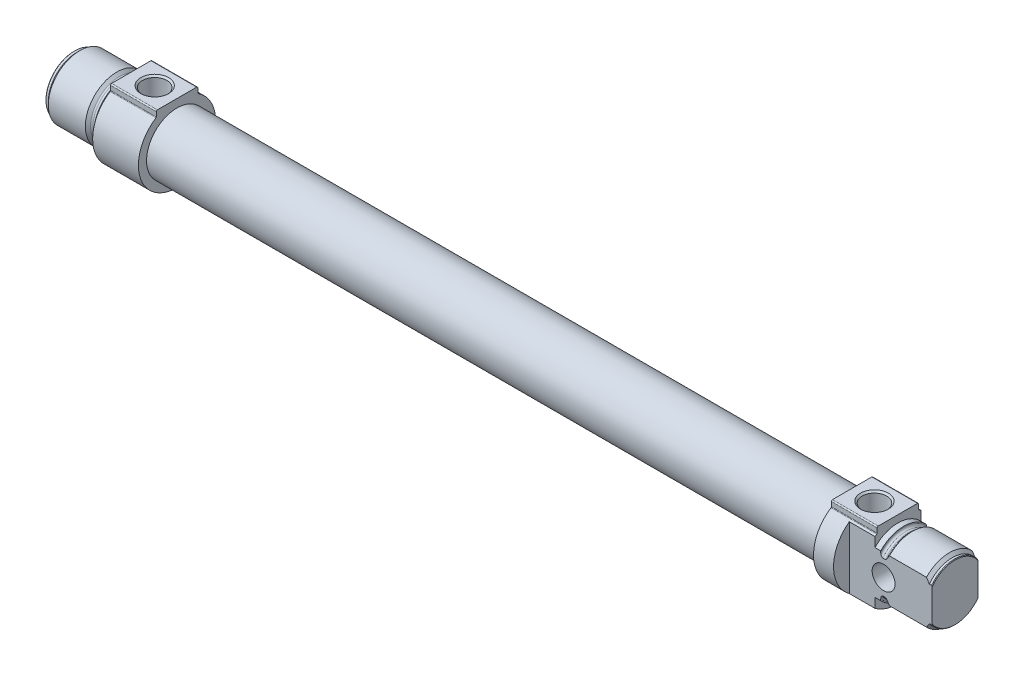
from build123d import *

# Parameters (mm, degrees)
AUFSATZ_LINEAR_AUSTRAGEN1_DEPTH      = 16
SKIZZE3_W                            = 236
SKIZZE3_H                            = 10.65
AUFSATZ_LINEAR_AUSTRAGEN2_DEPTH      = 16
SCHNITT_LINEAR_AUSTRAGEN1_DEPTH      = 13.5
SCHNITT_LINEAR_AUSTRAGEN1_DEPTH_BACK = 13.5
BOHRUNG1_D                           = 8
BOHRUNG2_D                           = 8.566
BOHRUNG2_DEPTH                       = 13.5
BOHRUNG2_CSINK_D                     = 9.728
BOHRUNG2_CSINK_ANGLE                 = 90
BOHRUNG3_D                           = 8.566
BOHRUNG3_DEPTH                       = 16
BOHRUNG3_CSINK_D                     = 9.728
BOHRUNG3_CSINK_ANGLE                 = 90
BOHRUNG3_TIP                         = 2.472791203


with BuildPart() as part:
    # Skizze1 → Rotation1 (revolve)
    with BuildSketch(Plane.XY):
        with BuildLine():
            Line((0, 0), (0, 9.8))
            Line((0, 9.8), (0.2, 10))
            Line((0.2, 10), (1, 10))
            Line((1, 10), (2, 11))
            Line((2, 11), (14.95, 11))
            Line((14.95, 11), (15.865685425, 10.084314575))
            ThreePointArc((15.865685425, 10.084314575), (16.125224104, 9.910896374), (16.43137085, 9.85))
            Line((16.43137085, 9.85), (17.2, 9.85))
            ThreePointArc((17.2, 9.85), (17.765685425, 10.084314575), (18, 10.65))
            Line((18, 10.65), (18, 11))
            Line((18, 11), (20, 11))
            Line((20, 11), (20, 0))
            Line((20, 0), (0, 0))
        make_face()
    revolve(axis=Axis((20, 0, 0), (-1, 0, 0)))

    # Skizze2 → Aufsatz-Linear austragen1 (add)
    with BuildSketch(Plane(origin=(20, 0, 0), x_dir=(0, 0, -1), z_dir=(1, 0, 0))):
        with BuildLine():
            Line((7.25, 11.551515052), (7.25, 13.1))
            ThreePointArc((7.25, 13.1), (7.132842712, 13.382842712), (6.85, 13.5))
            Line((6.85, 13.5), (-6.85, 13.5))
            ThreePointArc((-6.85, 13.5), (-7.132842712, 13.382842712), (-7.25, 13.1))
            Line((-7.25, 13.1), (-7.25, 11.551515052))
            ThreePointArc((-7.25, 11.551515052), (-7.286144803, 11.408754992), (-7.385869565, 11.30039516))
            ThreePointArc((-7.385869565, 11.30039516), (0, -13.5), (7.385869565, 11.30039516))
            ThreePointArc((7.385869565, 11.30039516), (7.286144803, 11.408754992), (7.25, 11.551515052))
        make_face()
    extrude(amount=AUFSATZ_LINEAR_AUSTRAGEN1_DEPTH)

    # Skizze3 → Rotation2 (revolve)
    with BuildSketch(Plane.XY):
        with Locations((154, 5.325)):
            Rectangle(SKIZZE3_W, SKIZZE3_H)
    revolve(axis=Axis((272, 0, 0), (-1, 0, 0)))

    # Skizze4 → Aufsatz-Linear austragen2 (add)
    with BuildSketch(Plane(origin=(272, 0, 0), x_dir=(0, 0, -1), z_dir=(1, 0, 0))):
        with BuildLine():
            Line((7.25, 11.551515052), (7.25, 13.1))
            ThreePointArc((7.25, 13.1), (7.132842712, 13.382842712), (6.85, 13.5))
            Line((6.85, 13.5), (-6.85, 13.5))
            ThreePointArc((-6.85, 13.5), (-7.132842712, 13.382842712), (-7.25, 13.1))
            Line((-7.25, 13.1), (-7.25, 11.551515052))
            ThreePointArc((-7.25, 11.551515052), (-7.286144803, 11.408754992), (-7.385869565, 11.30039516))
            ThreePointArc((-7.385869565, 11.30039516), (0, -13.5), (7.385869565, 11.30039516))
            ThreePointArc((7.385869565, 11.30039516), (7.286144803, 11.408754992), (7.25, 11.551515052))
        make_face()
    extrude(amount=AUFSATZ_LINEAR_AUSTRAGEN2_DEPTH)

    # Skizze5 → Rotation3 (revolve)
    with BuildSketch(Plane.XY):
        with BuildLine():
            Line((288, 0), (288, 11))
            Line((288, 11), (290, 11))
            Line((290, 11), (290, 10.65))
            ThreePointArc((290, 10.65), (290.234314575, 10.084314575), (290.8, 9.85))
            Line((290.8, 9.85), (291.56862915, 9.85))
            ThreePointArc((291.56862915, 9.85), (291.874775896, 9.910896374), (292.134314575, 10.084314575))
            Line((292.134314575, 10.084314575), (293.05, 11))
            Line((293.05, 11), (306, 11))
            Line((306, 11), (307, 10))
            Line((307, 10), (307.8, 10))
            Line((307.8, 10), (308, 9.8))
            Line((308, 9.8), (308, 0))
            Line((308, 0), (288, 0))
        make_face()
    revolve(axis=Axis((308, 0, 0), (-1, 0, 0)))

    # Skizze6 → Schnitt-Linear austragen1 (cut, two sides: drawn at the far end of the back side and taken through both)
    with BuildSketch(Plane(origin=(0, 0, 0), x_dir=(1, 0, 0), z_dir=(0, 1, 0)).offset(-SCHNITT_LINEAR_AUSTRAGEN1_DEPTH_BACK)):
        Polygon((279, 24), (279, 8), (308, 8), (308, -8), (279, -8), (279, -24), (324, -24), (324, 24), align=None)
    extrude(amount=SCHNITT_LINEAR_AUSTRAGEN1_DEPTH + SCHNITT_LINEAR_AUSTRAGEN1_DEPTH_BACK, mode=Mode.SUBTRACT)

    # Bohrung1 (through all)
    with Locations(Plane(origin=(0, 0, -8), x_dir=(-1, 0, 0), z_dir=(0, 0, -1))):
        with Locations((-291, 0)):
            Hole(BOHRUNG1_D / 2)

    # Bohrung2
    with Locations(Plane(origin=(0, 13.5, 0), x_dir=(1, 0, 0), z_dir=(0, 1, 0))):
        with Locations((28.2, 0)):
            CounterSinkHole(BOHRUNG2_D / 2, BOHRUNG2_CSINK_D / 2, depth=BOHRUNG2_DEPTH, counter_sink_angle=BOHRUNG2_CSINK_ANGLE)

    # Bohrung3
    with Locations(Plane(origin=(0, 13.5, 0), x_dir=(1, 0, 0), z_dir=(0, 1, 0))):
        with Locations((279.8, 0)):
            CounterSinkHole(BOHRUNG3_D / 2, BOHRUNG3_CSINK_D / 2, depth=BOHRUNG3_DEPTH, counter_sink_angle=BOHRUNG3_CSINK_ANGLE)
            with Locations((0, 0, -(BOHRUNG3_DEPTH + BOHRUNG3_TIP / 2))):  # 120° drill point
                Cone(0, BOHRUNG3_D / 2, BOHRUNG3_TIP, mode=Mode.SUBTRACT)

    # Skizze13 → Schnitt-Rotation1 (revolve, cut)
    with BuildSketch(Plane.XY):
        Polygon((-4, 0), (-4, 4), (50.3, 4), (50.3, 10), (255.3, 10), (255.3, 0), align=None)
    revolve(axis=Axis((255.3, 0, 0), (-1, 0, 0)), mode=Mode.SUBTRACT)


solid = part.part
